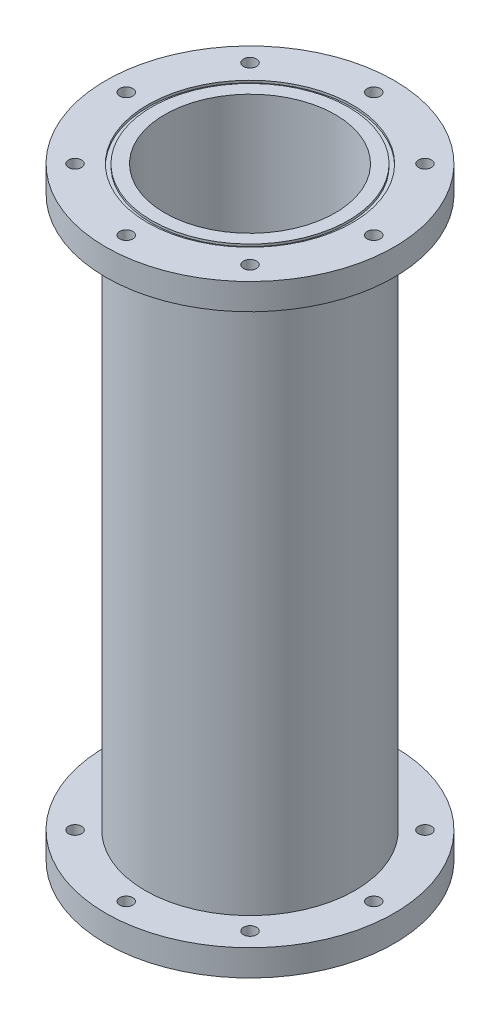
from build123d import *

# Parameters (mm, degrees)
SKETCH2_R               = 50.8
SKETCH2_R_2             = 41.275
BASE_CYLINDER_DEPTH     = 292.1
SKETCH3_R               = 69.85
SKETCH3_R_2             = 41.275
AFT_FLANGE_DEPTH        = 12.7
SKETCH4_R               = 69.85
SKETCH4_R_2             = 41.275
FORWARD_FLANGE_DEPTH    = 12.7
SKETCH6_R               = 49.53
SKETCH6_R_2             = 47.625
O_RING_SLOT_1_DEPTH     = 1.1176
SKETCH7_R               = 49.53
SKETCH7_R_2             = 47.625
O_RING_SLOT_2_DEPTH     = 1.1176
SKETCH8_R               = 3.175
CUT_EXTRUDE4_DEPTH      = 1
CUT_EXTRUDE4_DEPTH_BACK = 293.1


with BuildPart() as part:
    # Sketch2 → Base Cylinder (new body)
    with BuildSketch(Plane(origin=(0, 0, 0), x_dir=(1, 0, 0), z_dir=(0, 1, 0))):
        Circle(SKETCH2_R)
        Circle(SKETCH2_R_2, mode=Mode.SUBTRACT)
    extrude(amount=BASE_CYLINDER_DEPTH)

    # Sketch3 → Aft Flange (add)
    with BuildSketch(Plane.XZ):
        Circle(SKETCH3_R)
        Circle(SKETCH3_R_2, mode=Mode.SUBTRACT)
    extrude(amount=-AFT_FLANGE_DEPTH)

    # Sketch4 → Forward Flange (add)
    with BuildSketch(Plane(origin=(0, 292.1, 0), x_dir=(1, 0, 0), z_dir=(0, 1, 0))):
        Circle(SKETCH4_R)
        Circle(SKETCH4_R_2, mode=Mode.SUBTRACT)
    extrude(amount=-FORWARD_FLANGE_DEPTH)

    # Sketch6 → O-Ring Slot 1 (cut)
    with BuildSketch(Plane.XZ):
        Circle(SKETCH6_R)
        Circle(SKETCH6_R_2, mode=Mode.SUBTRACT)
    extrude(amount=-O_RING_SLOT_1_DEPTH, mode=Mode.SUBTRACT)

    # Sketch7 → O-Ring Slot 2 (cut)
    with BuildSketch(Plane(origin=(0, 292.1, 0), x_dir=(1, 0, 0), z_dir=(0, 1, 0))):
        Circle(SKETCH7_R)
        Circle(SKETCH7_R_2, mode=Mode.SUBTRACT)
    extrude(amount=-O_RING_SLOT_2_DEPTH, mode=Mode.SUBTRACT)

    # Sketch8 → Cut-Extrude4 (cut, two sides)
    with BuildSketch(Plane.XZ) as cut_extrude4_sk:
        with Locations((-59.9186, 0)):
            Circle(SKETCH8_R)
        with Locations((-42.368848379, 42.368848379)):
            Circle(SKETCH8_R)
        with Locations((0, 59.9186)):
            Circle(SKETCH8_R)
        with Locations((42.368848379, 42.368848379)):
            Circle(SKETCH8_R)
        with Locations((59.9186, 0)):
            Circle(SKETCH8_R)
        with Locations((42.368848379, -42.368848379)):
            Circle(SKETCH8_R)
        with Locations((0, -59.9186)):
            Circle(SKETCH8_R)
        with Locations((-42.368848379, -42.368848379)):
            Circle(SKETCH8_R)
    extrude(amount=CUT_EXTRUDE4_DEPTH, mode=Mode.SUBTRACT)
    extrude(cut_extrude4_sk.sketch, amount=-CUT_EXTRUDE4_DEPTH_BACK, mode=Mode.SUBTRACT)


solid = part.part
